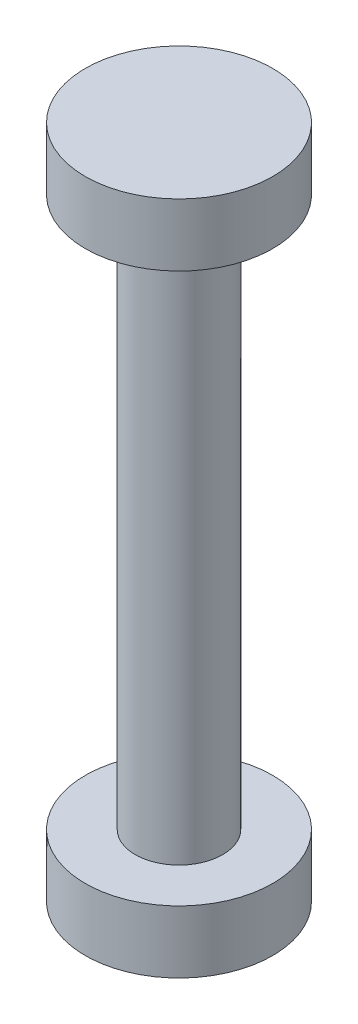
from build123d import *

# Parameters (mm, degrees)
SKETCH1_R           = 15
BOSS_EXTRUDE1_DEPTH = 10
SKETCH2_R           = 7
BOSS_EXTRUDE2_DEPTH = 98
SKETCH4_R           = 15
BOSS_EXTRUDE3_DEPTH = 10


with BuildPart() as part:
    # Sketch1 → Boss-Extrude1 (new body)
    with BuildSketch(Plane(origin=(0, 0, 0), x_dir=(1, 0, 0), z_dir=(0, 1, 0))):
        Circle(SKETCH1_R)
    extrude(amount=-BOSS_EXTRUDE1_DEPTH)

    # Sketch2 → Boss-Extrude2 (add)
    with BuildSketch(Plane.XZ.offset(10)):
        Circle(SKETCH2_R)
    extrude(amount=BOSS_EXTRUDE2_DEPTH)

    # Sketch4 → Boss-Extrude3 (add)
    with BuildSketch(Plane.XZ.offset(108)):
        Circle(SKETCH4_R)
    extrude(amount=-BOSS_EXTRUDE3_DEPTH)


solid = part.part
